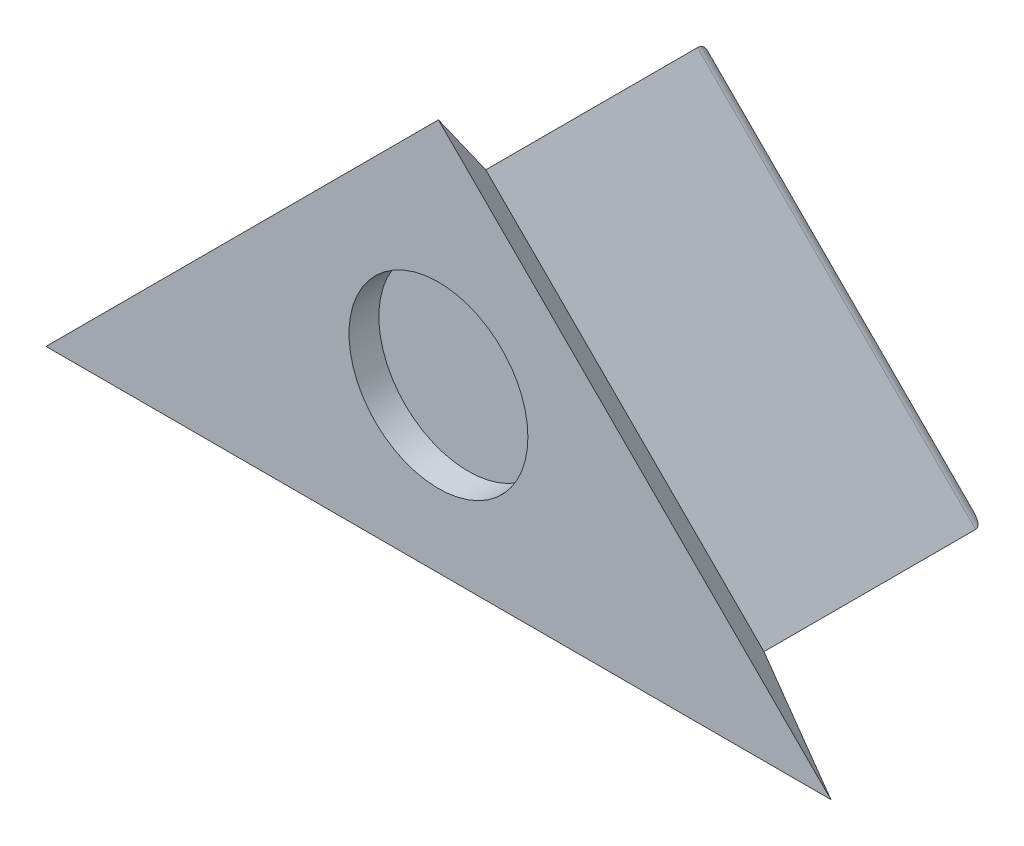
from build123d import *

# Parameters (mm, degrees)
BOSS_EXTRUDE1_DEPTH = 7.5
FILLET1_R           = 0.4
SKETCH3_R           = 3
CUT_EXTRUDE2_DEPTH  = 1


with BuildPart() as part:
    # Sketch1 → Boss-Extrude1 (new body)
    with BuildSketch(Plane.XY):
        Polygon((9.332731301, -89.971589642), (0, -80.638858341), (-9.332731301, -89.971589642), align=None)
    extrude(amount=-BOSS_EXTRUDE1_DEPTH)

    # Sketch2 → section 1 of loft1
    with BuildSketch(Plane.XY.offset(1.5875), mode=Mode.PRIVATE) as loft1_s1:
        Polygon((-13.165295331, -91.559089642), (13.165295331, -91.559089642), (0, -78.393794311), align=None)
    # loft from a face of the part (loft1)
    loft([part.faces().sort_by_distance((0, -86.860679209, 0))[0], loft1_s1.sketch])

    # Fillet1
    fillet1_edges = [part.edges().sort_by_distance(p)[0] for p in [
        (-4.666365651, -85.305223992, -7.5),
        (0, -89.971589642, -7.5),
        (4.666365651, -85.305223992, -7.5),
    ]]
    fillet(fillet1_edges, radius=FILLET1_R)

    # Sketch3 → Cut-Extrude2 (cut)
    with BuildSketch(Plane.XY.offset(1.5875)):
        with Locations((0, -86.105845763)):
            Circle(SKETCH3_R)
    extrude(amount=-CUT_EXTRUDE2_DEPTH, mode=Mode.SUBTRACT)


solid = part.part
